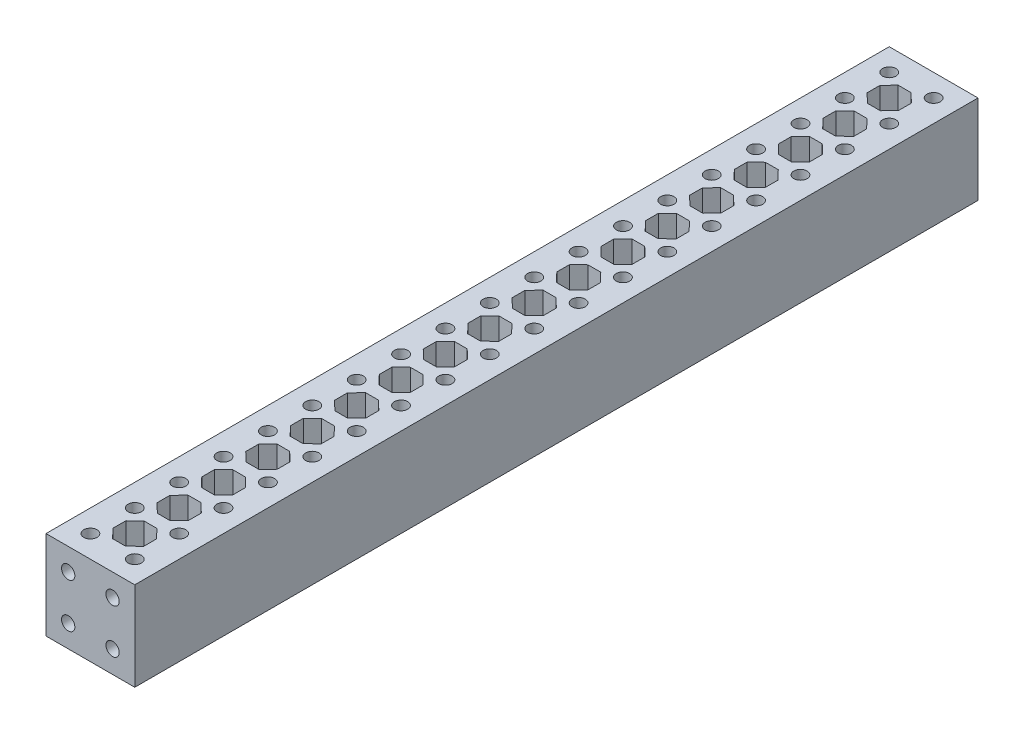
from build123d import *

# Parameters (mm, degrees)
SKETCH1_W           = 20
SKETCH1_H           = 20
BOSS_EXTRUDE1_DEPTH = 190
SKETCH2_R           = 1.5
CUT_EXTRUDE2_DEPTH  = 20
SKETCH3_R           = 1.5
CUT_EXTRUDE3_DEPTH  = 5


with BuildPart() as part:
    # Sketch1 → Boss-Extrude1 (new body)
    with BuildSketch(Plane.XY):
        with Locations((10, 10)):
            Rectangle(SKETCH1_W, SKETCH1_H)
    extrude(amount=BOSS_EXTRUDE1_DEPTH)

    # Sketch2 → Cut-Extrude2 (cut)
    with BuildSketch(Plane(origin=(0, 20, 0), x_dir=(1, 0, 0), z_dir=(0, 1, 0))):
        with Locations((15, -185)):
            Circle(SKETCH2_R)
        with Locations((15, -175)):
            Circle(SKETCH2_R)
        with Locations((15, -165)):
            Circle(SKETCH2_R)
        with Locations((15, -155)):
            Circle(SKETCH2_R)
        with Locations((15, -145)):
            Circle(SKETCH2_R)
        with Locations((15, -135)):
            Circle(SKETCH2_R)
        with Locations((15, -125)):
            Circle(SKETCH2_R)
        with Locations((15, -115)):
            Circle(SKETCH2_R)
        with Locations((15, -105)):
            Circle(SKETCH2_R)
        with Locations((15, -95)):
            Circle(SKETCH2_R)
        with Locations((15, -85)):
            Circle(SKETCH2_R)
        with Locations((15, -75)):
            Circle(SKETCH2_R)
        with Locations((15, -65)):
            Circle(SKETCH2_R)
        with Locations((15, -55)):
            Circle(SKETCH2_R)
        with Locations((15, -45)):
            Circle(SKETCH2_R)
        with Locations((15, -35)):
            Circle(SKETCH2_R)
        with Locations((15, -25)):
            Circle(SKETCH2_R)
        with Locations((15, -15)):
            Circle(SKETCH2_R)
        with Locations((15, -5)):
            Circle(SKETCH2_R)
        with Locations((5, -5)):
            Circle(SKETCH2_R)
        with Locations((5, -15)):
            Circle(SKETCH2_R)
        with Locations((5, -25)):
            Circle(SKETCH2_R)
        with Locations((5, -35)):
            Circle(SKETCH2_R)
        with Locations((5, -45)):
            Circle(SKETCH2_R)
        with Locations((5, -55)):
            Circle(SKETCH2_R)
        with Locations((5, -65)):
            Circle(SKETCH2_R)
        with Locations((5, -75)):
            Circle(SKETCH2_R)
        with Locations((5, -85)):
            Circle(SKETCH2_R)
        with Locations((5, -95)):
            Circle(SKETCH2_R)
        with Locations((5, -105)):
            Circle(SKETCH2_R)
        with Locations((5, -115)):
            Circle(SKETCH2_R)
        with Locations((5, -125)):
            Circle(SKETCH2_R)
        with Locations((5, -135)):
            Circle(SKETCH2_R)
        with Locations((5, -145)):
            Circle(SKETCH2_R)
        with Locations((5, -155)):
            Circle(SKETCH2_R)
        with Locations((5, -165)):
            Circle(SKETCH2_R)
        with Locations((5, -175)):
            Circle(SKETCH2_R)
        with Locations((5, -185)):
            Circle(SKETCH2_R)
        Polygon((8.5, -183.5), (11.4, -183.5), (13.5, -181.5), (13.5, -178.6), (11.5, -176.5), (8.6, -176.5), (6.5, -178.5), (6.5, -181.4), align=None)
        Polygon((6.5, -171.5), (6.5, -168.6), (8.5, -166.5), (11.4, -166.5), (13.5, -168.5), (13.5, -171.4), (11.5, -173.5), (8.6, -173.5), align=None)
        Polygon((8.6, -156.5), (6.5, -158.5), (6.5, -161.4), (8.5, -163.5), (11.4, -163.5), (13.5, -161.5), (13.5, -158.6), (11.5, -156.5), align=None)
        Polygon((11.5, -153.5), (8.6, -153.5), (6.5, -151.5), (6.5, -148.6), (8.5, -146.5), (11.4, -146.5), (13.5, -148.5), (13.5, -151.4), align=None)
        Polygon((13.5, -138.6), (11.5, -136.5), (8.6, -136.5), (6.5, -138.5), (6.5, -141.4), (8.5, -143.5), (11.4, -143.5), (13.5, -141.5), align=None)
        Polygon((13.5, -128.5), (13.5, -131.4), (11.5, -133.5), (8.6, -133.5), (6.5, -131.5), (6.5, -128.6), (8.5, -126.5), (11.4, -126.5), align=None)
        Polygon((11.4, -123.5), (13.5, -121.5), (13.5, -118.6), (11.5, -116.5), (8.6, -116.5), (6.5, -118.5), (6.5, -121.4), (8.5, -123.5), align=None)
        Polygon((8.5, -106.5), (11.4, -106.5), (13.5, -108.5), (13.5, -111.4), (11.5, -113.5), (8.6, -113.5), (6.5, -111.5), (6.5, -108.6), align=None)
        Polygon((6.5, -101.4), (8.5, -103.5), (11.4, -103.5), (13.5, -101.5), (13.5, -98.6), (11.5, -96.5), (8.6, -96.5), (6.5, -98.5), align=None)
        Polygon((6.5, -91.5), (6.5, -88.6), (8.5, -86.5), (11.4, -86.5), (13.5, -88.5), (13.5, -91.4), (11.5, -93.5), (8.6, -93.5), align=None)
        Polygon((8.6, -76.5), (6.5, -78.5), (6.5, -81.4), (8.5, -83.5), (11.4, -83.5), (13.5, -81.5), (13.5, -78.6), (11.5, -76.5), align=None)
        Polygon((11.5, -73.5), (8.6, -73.5), (6.5, -71.5), (6.5, -68.6), (8.5, -66.5), (11.4, -66.5), (13.5, -68.5), (13.5, -71.4), align=None)
        Polygon((13.5, -58.6), (11.5, -56.5), (8.6, -56.5), (6.5, -58.5), (6.5, -61.4), (8.5, -63.5), (11.4, -63.5), (13.5, -61.5), align=None)
        Polygon((13.5, -48.5), (13.5, -51.4), (11.5, -53.5), (8.6, -53.5), (6.5, -51.5), (6.5, -48.6), (8.5, -46.5), (11.4, -46.5), align=None)
        Polygon((11.4, -43.5), (13.5, -41.5), (13.5, -38.6), (11.5, -36.5), (8.6, -36.5), (6.5, -38.5), (6.5, -41.4), (8.5, -43.5), align=None)
        Polygon((8.5, -26.5), (11.4, -26.5), (13.5, -28.5), (13.5, -31.4), (11.5, -33.5), (8.6, -33.5), (6.5, -31.5), (6.5, -28.6), align=None)
        Polygon((6.5, -21.4), (8.5, -23.5), (11.4, -23.5), (13.5, -21.5), (13.5, -18.6), (11.5, -16.5), (8.6, -16.5), (6.5, -18.5), align=None)
        Polygon((6.5, -11.5), (6.5, -8.6), (8.5, -6.5), (11.4, -6.5), (13.5, -8.5), (13.5, -11.4), (11.5, -13.5), (8.6, -13.5), align=None)
    extrude(amount=-CUT_EXTRUDE2_DEPTH, mode=Mode.SUBTRACT)

    # Sketch3 → Cut-Extrude3 (cut)
    with BuildSketch(Plane.XY.offset(190)):
        with Locations((15, 15)):
            Circle(SKETCH3_R)
        with Locations((15, 5)):
            Circle(SKETCH3_R)
        with Locations((5, 5)):
            Circle(SKETCH3_R)
        with Locations((5, 15)):
            Circle(SKETCH3_R)
    extrude(amount=-CUT_EXTRUDE3_DEPTH, mode=Mode.SUBTRACT)


solid = part.part
